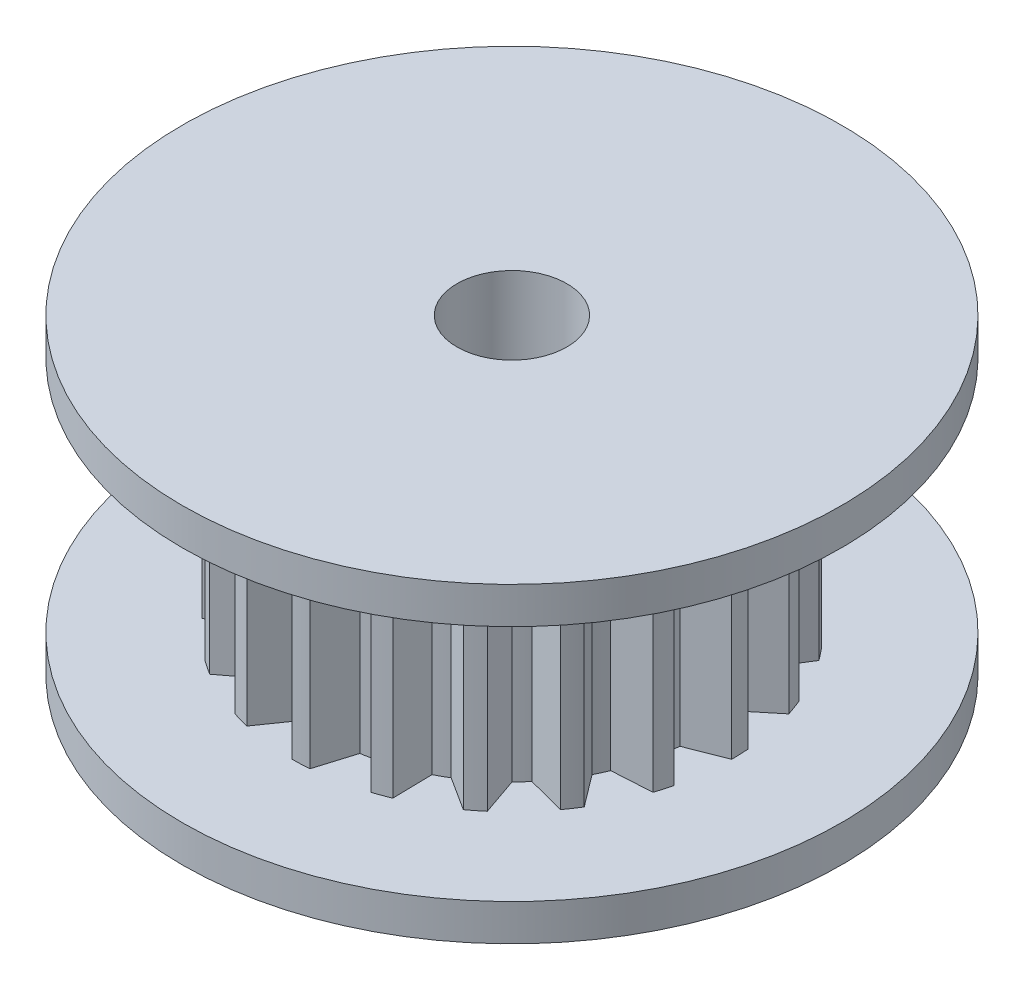
from build123d import *

# Parameters (mm, degrees)
SKETCH_1_R          = 9
EXTRUDE_1_DEPTH     = 1
SKETCH_2_R          = 6
EXTRUDE_2_DEPTH     = 6.5
SKETCH_3_R          = 9
EXTRUDE_3_DEPTH     = 1
SKETCH_4_R          = 1.5
CUT_EXTRUDE_1_DEPTH = 9.5
CUT_EXTRUDE_2_DEPTH = 6.5


with BuildPart() as part:
    # 草图1 → 凸台-拉伸1 (new body)
    with BuildSketch(Plane(origin=(0, 0, 0), x_dir=(1, 0, 0), z_dir=(0, 1, 0))):
        Circle(SKETCH_1_R)
    extrude(amount=EXTRUDE_1_DEPTH)

    # 草图2 → 凸台-拉伸2 (add)
    with BuildSketch(Plane(origin=(0, 1, 0), x_dir=(1, 0, 0), z_dir=(0, 1, 0))):
        Circle(SKETCH_2_R)
    extrude(amount=EXTRUDE_2_DEPTH)

    # 草图3 → 凸台-拉伸3 (add)
    with BuildSketch(Plane(origin=(0, 7.5, 0), x_dir=(1, 0, 0), z_dir=(0, 1, 0))):
        Circle(SKETCH_3_R)
    extrude(amount=EXTRUDE_3_DEPTH)

    # 草图4 → 切除-拉伸1 (cut, through all)
    with BuildSketch(Plane(origin=(0, 8.5, 0), x_dir=(1, 0, 0), z_dir=(0, 1, 0))):
        Circle(SKETCH_4_R)
    extrude(amount=-CUT_EXTRUDE_1_DEPTH, mode=Mode.SUBTRACT)

    # 草图5 → 切除-拉伸2 (cut)
    with BuildSketch(Plane(origin=(0, 1, 0), x_dir=(1, 0, 0), z_dir=(0, 1, 0))):
        with BuildLine():
            Line((-6, 0), (-4.984088538, 0.398574263))
            ThreePointArc((-4.984088538, 0.398574263), (-4.96506054, 0.590062568), (-4.938678327, 0.780676876))
            Line((-4.938678327, 0.780676876), (-5.83314158, 1.40515455))
            ThreePointArc((-5.83314158, 1.40515455), (-5.958139369, 0.707513435), (-6, 0))
        make_face()
        with BuildLine():
            Line((-5.981863946, -0.466158487), (-4.938204626, -0.783667703))
            ThreePointArc((-4.938204626, -0.783667703), (-4.904392542, -0.973105234), (-4.863316103, -1.161101409))
            Line((-4.863316103, -1.161101409), (-5.706339098, -1.854101966))
            ThreePointArc((-5.706339098, -1.854101966), (-5.885160947, -1.168281057), (-5.981863946, -0.466158487))
        make_face()
        with BuildLine():
            Line((-5.706339098, 1.854101966), (-4.616983661, 1.91923471))
            ThreePointArc((-4.616983661, 1.91923471), (-4.539713819, 2.095470935), (-4.455719783, 2.268603363))
            Line((-4.455719783, 2.268603363), (-5.113430674, 3.13892127))
            ThreePointArc((-5.113430674, 3.13892127), (-5.447893597, 2.514051583), (-5.706339098, 1.854101966))
        make_face()
        with BuildLine():
            Line((-4.854101966, 3.526711514), (-3.797936255, 3.252027091))
            ThreePointArc((-3.797936255, 3.252027091), (-3.669988279, 3.395760008), (-3.536604341, 3.534463146))
            Line((-3.536604341, 3.534463146), (-3.893181547, 4.565428506))
            ThreePointArc((-3.893181547, 4.565428506), (-4.404370041, 4.074496845), (-4.854101966, 3.526711514))
        make_face()
        with BuildLine():
            Line((-3.526711514, 4.854101966), (-2.607120386, 4.266488403))
            ThreePointArc((-2.607120386, 4.266488403), (-2.441018717, 4.36364843), (-2.271301426, 4.454345051))
            Line((-2.271301426, 4.454345051), (-2.291840684, 5.545039791))
            ThreePointArc((-2.291840684, 5.545039791), (-2.929716059, 5.236101967), (-3.526711514, 4.854101966))
        make_face()
        with BuildLine():
            Line((-1.854101966, 5.706339098), (-1.161101409, 4.863316103))
            ThreePointArc((-1.161101409, 4.863316103), (-0.973105234, 4.904392542), (-0.783667703, 4.938204626))
            Line((-0.783667703, 4.938204626), (-0.466158487, 5.981863946))
            ThreePointArc((-0.466158487, 5.981863946), (-1.168281057, 5.885160947), (-1.854101966, 5.706339098))
        make_face()
        with BuildLine():
            Line((0, 6), (0.398574263, 4.984088538))
            ThreePointArc((0.398574263, 4.984088538), (0.590062568, 4.96506054), (0.780676876, 4.938678327))
            Line((0.780676876, 4.938678327), (1.40515455, 5.83314158))
            ThreePointArc((1.40515455, 5.83314158), (0.707513435, 5.958139369), (0, 6))
        make_face()
        with BuildLine():
            Line((1.854101966, 5.706339098), (1.91923471, 4.616983661))
            ThreePointArc((1.91923471, 4.616983661), (2.095470935, 4.539713819), (2.268603363, 4.455719783))
            Line((2.268603363, 4.455719783), (3.13892127, 5.113430674))
            ThreePointArc((3.13892127, 5.113430674), (2.514051583, 5.447893597), (1.854101966, 5.706339098))
        make_face()
        with BuildLine():
            Line((3.526711514, 4.854101966), (3.252027091, 3.797936255))
            ThreePointArc((3.252027091, 3.797936255), (3.395760008, 3.669988279), (3.534463146, 3.536604341))
            Line((3.534463146, 3.536604341), (4.565428506, 3.893181547))
            ThreePointArc((4.565428506, 3.893181547), (4.074496845, 4.404370041), (3.526711514, 4.854101966))
        make_face()
        with BuildLine():
            Line((4.854101966, 3.526711514), (4.266488403, 2.607120386))
            ThreePointArc((4.266488403, 2.607120386), (4.36364843, 2.441018717), (4.454345051, 2.271301426))
            Line((4.454345051, 2.271301426), (5.545039791, 2.291840684))
            ThreePointArc((5.545039791, 2.291840684), (5.236101967, 2.929716059), (4.854101966, 3.526711514))
        make_face()
        with BuildLine():
            Line((5.706339098, 1.854101966), (4.863316103, 1.161101409))
            ThreePointArc((4.863316103, 1.161101409), (4.904392542, 0.973105234), (4.938204626, 0.783667703))
            Line((4.938204626, 0.783667703), (5.981863946, 0.466158487))
            ThreePointArc((5.981863946, 0.466158487), (5.885160947, 1.168281057), (5.706339098, 1.854101966))
        make_face()
        with BuildLine():
            Line((6, 0), (4.984088538, -0.398574263))
            ThreePointArc((4.984088538, -0.398574263), (4.96506054, -0.590062568), (4.938678327, -0.780676876))
            Line((4.938678327, -0.780676876), (5.83314158, -1.40515455))
            ThreePointArc((5.83314158, -1.40515455), (5.958139369, -0.707513435), (6, 0))
        make_face()
        with BuildLine():
            Line((5.706339098, -1.854101966), (4.616983661, -1.91923471))
            ThreePointArc((4.616983661, -1.91923471), (4.539713819, -2.095470935), (4.455719783, -2.268603363))
            Line((4.455719783, -2.268603363), (5.113430674, -3.13892127))
            ThreePointArc((5.113430674, -3.13892127), (5.447893597, -2.514051583), (5.706339098, -1.854101966))
        make_face()
        with BuildLine():
            Line((4.854101966, -3.526711514), (3.797936255, -3.252027091))
            ThreePointArc((3.797936255, -3.252027091), (3.669988279, -3.395760008), (3.536604341, -3.534463146))
            Line((3.536604341, -3.534463146), (3.893181547, -4.565428506))
            ThreePointArc((3.893181547, -4.565428506), (4.404370041, -4.074496845), (4.854101966, -3.526711514))
        make_face()
        with BuildLine():
            Line((3.526711514, -4.854101966), (2.607120386, -4.266488403))
            ThreePointArc((2.607120386, -4.266488403), (2.441018717, -4.36364843), (2.271301426, -4.454345051))
            Line((2.271301426, -4.454345051), (2.291840684, -5.545039791))
            ThreePointArc((2.291840684, -5.545039791), (2.929716059, -5.236101967), (3.526711514, -4.854101966))
        make_face()
        with BuildLine():
            Line((1.854101966, -5.706339098), (1.161101409, -4.863316103))
            ThreePointArc((1.161101409, -4.863316103), (0.973105234, -4.904392542), (0.783667703, -4.938204626))
            Line((0.783667703, -4.938204626), (0.466158487, -5.981863946))
            ThreePointArc((0.466158487, -5.981863946), (1.168281057, -5.885160947), (1.854101966, -5.706339098))
        make_face()
        with BuildLine():
            Line((0, -6), (-0.398574263, -4.984088538))
            ThreePointArc((-0.398574263, -4.984088538), (-0.590062568, -4.96506054), (-0.780676876, -4.938678327))
            Line((-0.780676876, -4.938678327), (-1.40515455, -5.83314158))
            ThreePointArc((-1.40515455, -5.83314158), (-0.707513435, -5.958139369), (0, -6))
        make_face()
        with BuildLine():
            Line((-1.854101966, -5.706339098), (-1.91923471, -4.616983661))
            ThreePointArc((-1.91923471, -4.616983661), (-2.095470935, -4.539713819), (-2.268603363, -4.455719783))
            Line((-2.268603363, -4.455719783), (-3.13892127, -5.113430674))
            ThreePointArc((-3.13892127, -5.113430674), (-2.514051583, -5.447893597), (-1.854101966, -5.706339098))
        make_face()
        with BuildLine():
            Line((-3.526711514, -4.854101966), (-3.252027091, -3.797936255))
            ThreePointArc((-3.252027091, -3.797936255), (-3.395760008, -3.669988279), (-3.534463146, -3.536604341))
            Line((-3.534463146, -3.536604341), (-4.565428506, -3.893181547))
            ThreePointArc((-4.565428506, -3.893181547), (-4.074496845, -4.404370041), (-3.526711514, -4.854101966))
        make_face()
        with BuildLine():
            Line((-4.854101966, -3.526711514), (-4.266488403, -2.607120386))
            ThreePointArc((-4.266488403, -2.607120386), (-4.36364843, -2.441018717), (-4.454345051, -2.271301426))
            Line((-4.454345051, -2.271301426), (-5.545039791, -2.291840684))
            ThreePointArc((-5.545039791, -2.291840684), (-5.236101967, -2.929716059), (-4.854101966, -3.526711514))
        make_face()
    extrude(amount=CUT_EXTRUDE_2_DEPTH, mode=Mode.SUBTRACT)


solid = part.part
